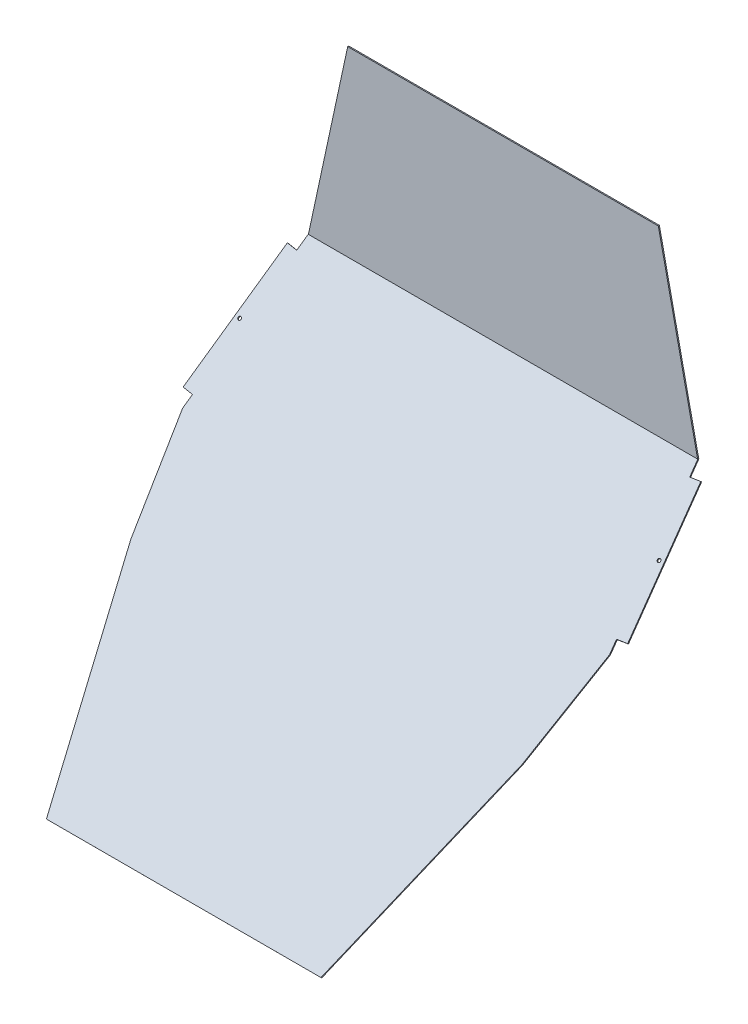
from build123d import *

# Parameters (mm, degrees)
UPPER_DEPTH = 1.5
SKETCH2_R   = 2.159
LOWER_DEPTH = 1.5


with BuildPart() as part:
    # Sketch1 → Upper (new body)
    with BuildSketch(Plane.XY):
        Polygon((-212.5, 0), (212.5, 0), (266.41785, -250), (-266.41785, -250), align=None)
    extrude(amount=UPPER_DEPTH)

    # Sketch2 → Lower (add)
    with BuildSketch(Plane(origin=(0, -125.523597244, -124.998903379), x_dir=(1, 0, 0), z_dir=(0, 0.70858619, 0.70562427))):
        Polygon((-187.8166, -793.662967608), (187.8166, -793.662967608), (267.44325, -518.175167608), (292.1, -383.391867608), (266.41785, -176.406067608), (-266.41785, -176.406067608), (-292.1, -383.391867608), (-267.44325, -518.175167608), align=None)
        Polygon((-290.093306858, -367.218884221), (-268.844696442, -195.965284898), (-282.847719378, -194.227833655), (-304.096329794, -365.481432978), align=None)
        with Locations((-286.940102201, -280.648769571)):
            Circle(SKETCH2_R, mode=Mode.SUBTRACT)
        Polygon((282.847719378, -194.227833655), (268.844696442, -195.965284898), (290.093306858, -367.218884221), (304.096329794, -365.481432978), align=None)
        with Locations((286.940102201, -280.648769571)):
            Circle(SKETCH2_R, mode=Mode.SUBTRACT)
    extrude(amount=LOWER_DEPTH)


solid = part.part
